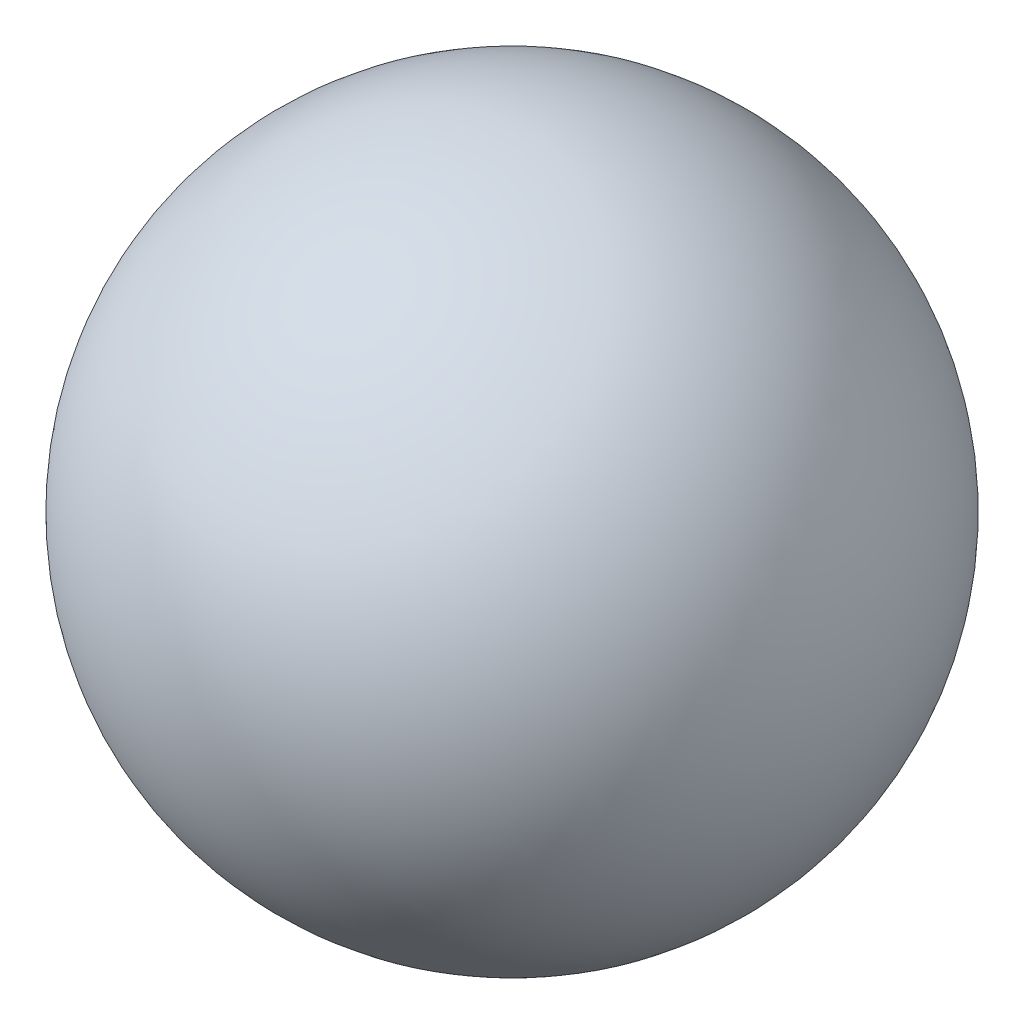
from build123d import *


with BuildPart() as part:
    # Sketch1 → Revolve1 (revolve)
    with BuildSketch(Plane.XY):
        with BuildLine():
            Line((0, 1620.000000024), (0, -1620.000000024))
            ThreePointArc((0, -1620.000000024), (1620.000000024, 0), (0, 1620.000000024))
        make_face()
    revolve(axis=Axis((0, 1620.000000024, 0), (0, -1, 0)))


solid = part.part
